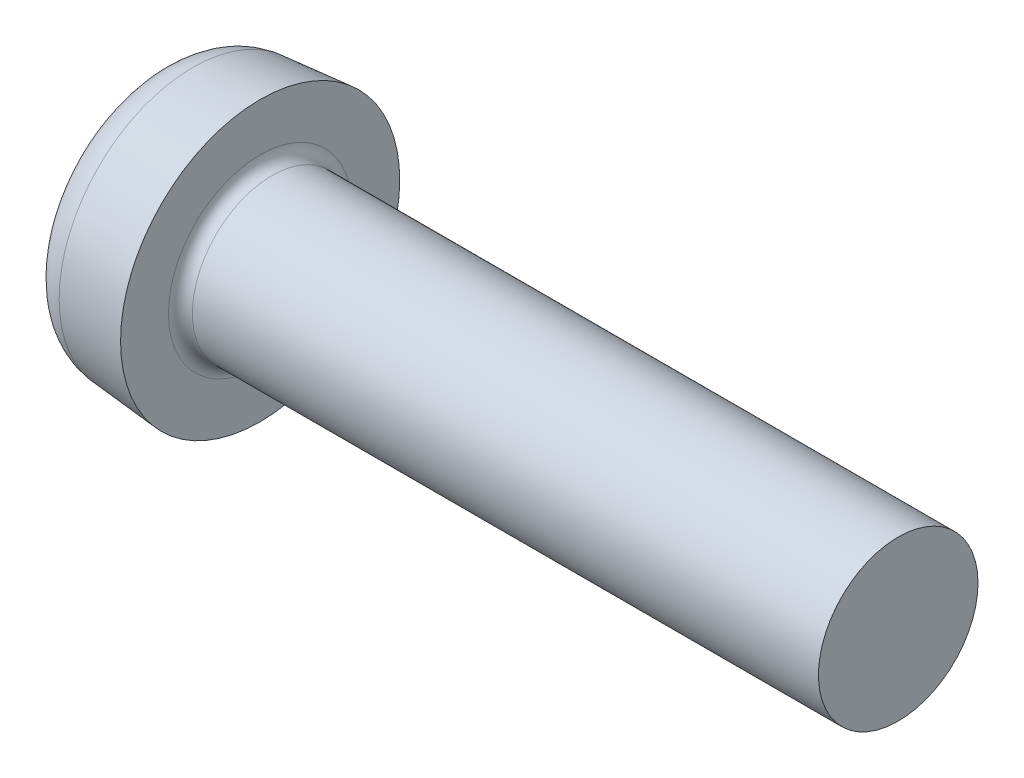
from build123d import *

# Parameters (mm, degrees)
CROSSRECESS_DEPTH = 2.6
FILLET5_R         = 0.3
HEADFILLET_R      = 1
DRAFT1_ANGLE      = 20


with BuildPart() as part:
    # Sketch1 → Base (revolve)
    with BuildSketch(Plane.XY):
        with BuildLine():
            Line((18.6, 2), (4, 2))
            Line((4, 2), (2.9, 2))
            ThreePointArc((2.9, 2), (2.687867966, 2.087867966), (2.6, 2.3))
            Line((2.6, 2.3), (2.6, 3.5))
            Line((2.6, 3.5), (0, 3.272529475))
            Line((0, 3.272529475), (0, 0))
            Line((0, 0), (18.6, 0))
            Line((18.6, 0), (18.6, 2))
        make_face()
    revolve(axis=Axis((4.515812911, 0, 0), (-1, 0, 0)))

    # Sketch6 → CrossRecess (cut)
    with BuildSketch(Plane(origin=(0, 0, 0), x_dir=(0, 0, -1), z_dir=(1, 0, 0))):
        Polygon((0.41, 0.41), (0.41, 2.05), (-0.41, 2.05), (-0.41, 0.41), (-2.05, 0.41), (-2.05, -0.41), (-0.41, -0.41), (-0.41, -2.05), (0.41, -2.05), (0.41, -0.41), (2.05, -0.41), (2.05, 0.41), align=None)
    extrude(amount=CROSSRECESS_DEPTH, mode=Mode.SUBTRACT)

    # Fillet5
    fillet5_edges = [part.edges().sort_by_distance(p)[0] for p in [
        (1.3, 0.41, 0.41),
        (1.3, -0.41, 0.41),
        (1.3, -0.41, -0.41),
        (1.3, 0.41, -0.41),
    ]]
    fillet(fillet5_edges, radius=FILLET5_R)

    # HeadFillet
    headfillet_edges = [part.edges().sort_by_distance(p)[0] for p in [
        (0, -3.272529475, 0),
    ]]
    fillet(headfillet_edges, radius=HEADFILLET_R)

    # Draft1
    draft1_faces = [part.faces().sort_by_distance(p)[0] for p in [
        (1.3, 0, 2.05),
        (1.3, -2.05, 0),
        (1.3, 0, -2.05),
        (1.3, 2.05, 0),
    ]]
    draft(draft1_faces, Plane(origin=(0, 0, 0), x_dir=(0, 0, -1), z_dir=(-1, 0, 0)), DRAFT1_ANGLE)


solid = part.part
